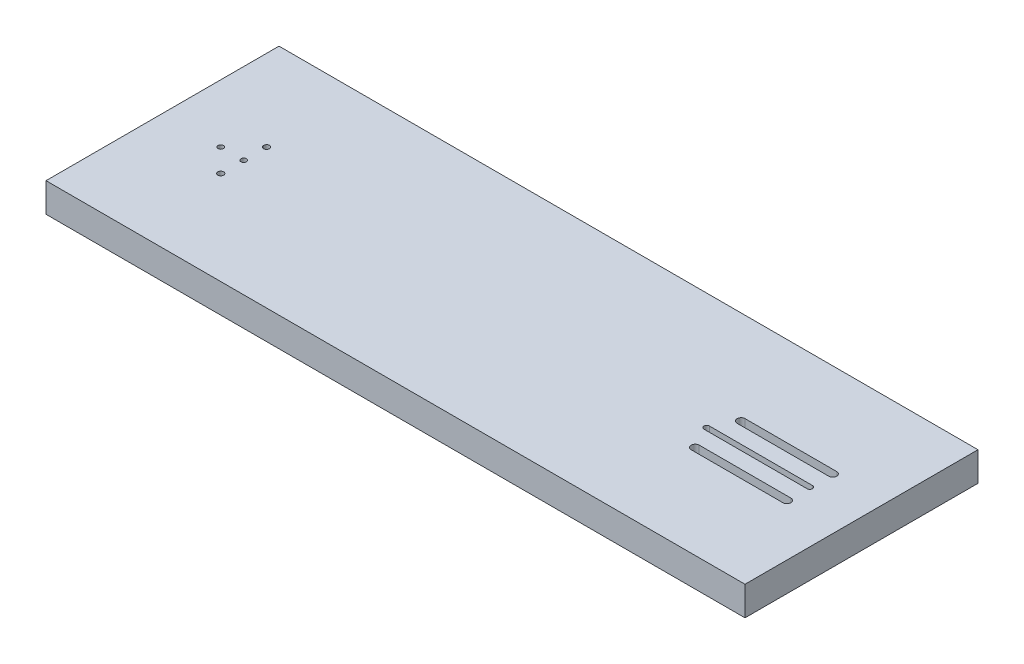
from build123d import *

# Parameters (mm, degrees)
SKETCH1_W           = 609.6
SKETCH1_H           = 203.2
BOSS_EXTRUDE1_DEPTH = 25.4
SKETCH2_R           = 2.3815
SKETCH2_R_2         = 2.5525
CUT_EXTRUDE2_DEPTH  = 26.4
CUT_EXTRUDE3_DEPTH  = 8


with BuildPart() as part:
    # Sketch1 → Boss-Extrude1 (new body)
    with BuildSketch(Plane(origin=(0, 0, 0), x_dir=(1, 0, 0), z_dir=(0, 1, 0))):
        with Locations((304.8, 101.6)):
            Rectangle(SKETCH1_W, SKETCH1_H)
    extrude(amount=BOSS_EXTRUDE1_DEPTH)

    # Sketch2 → Cut-Extrude2 (cut, through all)
    with BuildSketch(Plane(origin=(0, 25.4, 0), x_dir=(1, 0, 0), z_dir=(0, 1, 0))):
        with Locations(Location((50.8, 101.6, 0), (0, 0, 270))):  # turned: the seam where the file's is
            Circle(SKETCH2_R)
        with Locations(Location((70.8, 101.6, 0), (0, 0, 270))):  # turned: the seam where the file's is
            Circle(SKETCH2_R)
        with Locations(Location((70.8, 121.6, 0), (0, 0, 270))):  # turned: the seam where the file's is
            Circle(SKETCH2_R_2)
        with Locations(Location((70.8, 81.6, 0), (0, 0, 270))):  # turned: the seam where the file's is
            Circle(SKETCH2_R_2)
        with BuildLine():
            Line((474.530890234, 103.9815), (564.530890234, 103.9815))
            ThreePointArc((564.530890234, 103.9815), (566.912390234, 101.6), (564.530890234, 99.2185))
            Line((564.530890234, 99.2185), (474.530890234, 99.2185))
            ThreePointArc((474.530890234, 99.2185), (472.149390234, 101.6), (474.530890234, 103.9815))
        make_face()
        with BuildLine():
            Line((484.541340045, 125.1), (564.541340045, 125.1))
            ThreePointArc((564.541340045, 125.1), (568.041340045, 121.6), (564.541340045, 118.1))
            Line((564.541340045, 118.1), (484.541340045, 118.1))
            ThreePointArc((484.541340045, 118.1), (481.041340045, 121.6), (484.541340045, 125.1))
        make_face()
        with BuildLine():
            Line((484.541340045, 85.1), (564.541340045, 85.1))
            ThreePointArc((564.541340045, 85.1), (568.041340045, 81.6), (564.541340045, 78.1))
            Line((564.541340045, 78.1), (484.541340045, 78.1))
            ThreePointArc((484.541340045, 78.1), (481.041340045, 81.6), (484.541340045, 85.1))
        make_face()
    extrude(amount=-CUT_EXTRUDE2_DEPTH, mode=Mode.SUBTRACT)

    # Sketch7 → Cut-Extrude3 (cut)
    with BuildSketch(Plane.XZ):
        with BuildLine():
            Line((484.541340045, -76.1), (564.541340045, -76.1))
            ThreePointArc((564.541340045, -76.1), (570.041340045, -81.6), (564.541340045, -87.1))
            Line((564.541340045, -87.1), (484.541340045, -87.1))
            ThreePointArc((484.541340045, -87.1), (479.041340045, -81.6), (484.541340045, -76.1))
        make_face()
        with BuildLine():
            Line((484.541340045, -116.1), (564.541340045, -116.1))
            ThreePointArc((564.541340045, -116.1), (570.041340045, -121.6), (564.541340045, -127.1))
            Line((564.541340045, -127.1), (484.541340045, -127.1))
            ThreePointArc((484.541340045, -127.1), (479.041340045, -121.6), (484.541340045, -116.1))
        make_face()
    extrude(amount=-CUT_EXTRUDE3_DEPTH, mode=Mode.SUBTRACT)


solid = part.part
